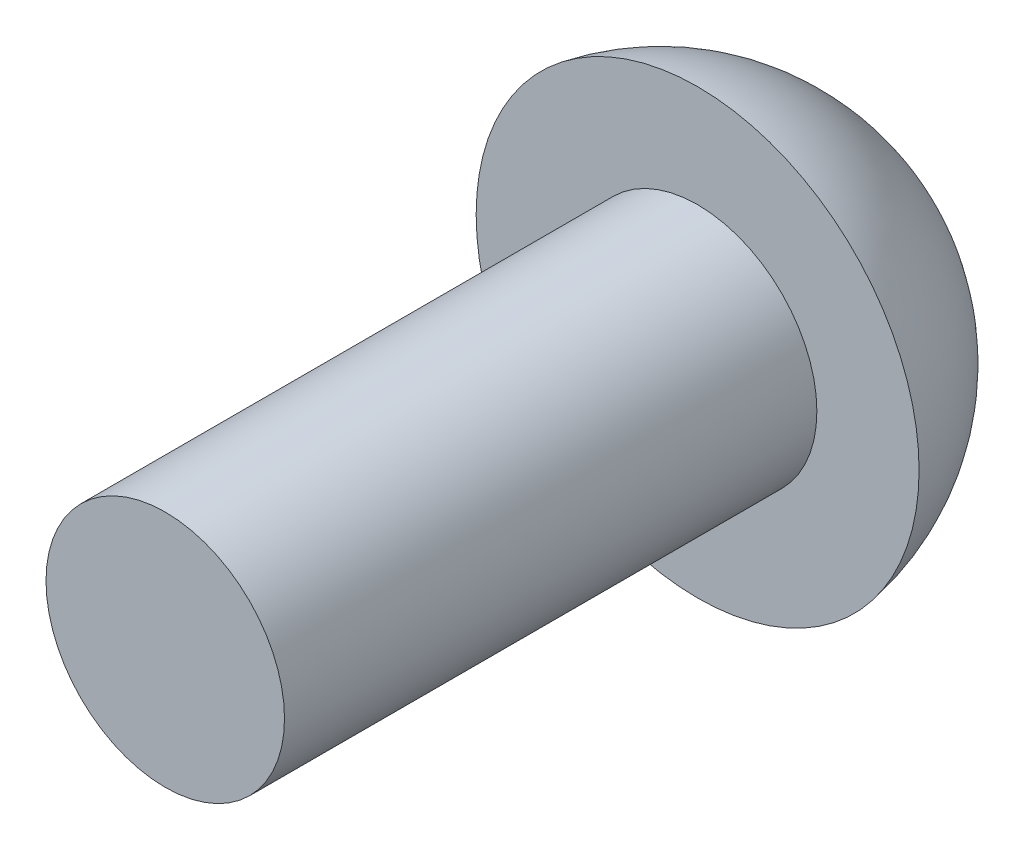
from build123d import *


with BuildPart() as part:
    # Sketch2 → Revolve1 (revolve)
    with BuildSketch(Plane(origin=(0, 0, 0), x_dir=(0, 0, -1), z_dir=(1, 0, 0))):
        with BuildLine():
            Line((0, 0), (0, 1.4224))
            Line((0, 1.4224), (6.35, 1.4224))
            Line((6.35, 1.4224), (6.35, 2.6416))
            ThreePointArc((6.35, 2.6416), (7.95141941, 1.730185655), (8.5852, 0))
            Line((8.5852, 0), (0, 0))
        make_face()
    revolve(axis=Axis((0, 0, 0), (0, 0, -1)))


solid = part.part
